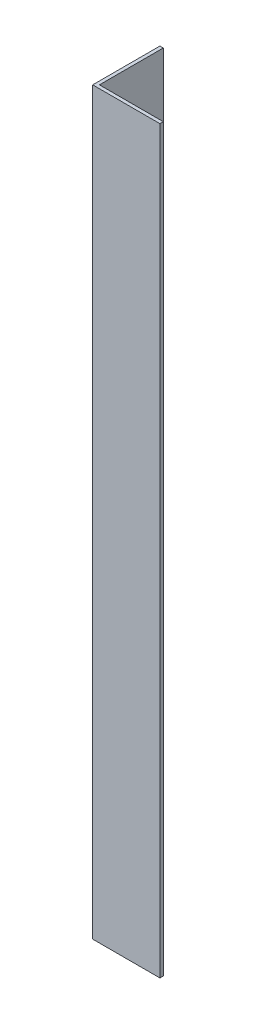
from build123d import *

# Parameters (mm, degrees)
EXTRUDE_1_DEPTH     = 220
SKETCH_2_R          = 4.25
CUT_EXTRUDE_1_DEPTH = 2


with BuildPart() as part:
    # Эскиз1 → Бобышка-Вытянуть1 (new body)
    with BuildSketch(Plane(origin=(0, 0, 0), x_dir=(1, 0, 0), z_dir=(0, 1, 0))):
        Polygon((0, 0), (0, 20), (1, 20), (1, 1), (20, 1), (20, 0), align=None)
    extrude(amount=EXTRUDE_1_DEPTH)

    # Эскиз2 → Вырез-Вытянуть1 (cut, through all)
    with BuildSketch(Plane(origin=(1, 0, 0), x_dir=(0, 0, -1), z_dir=(1, 0, 0))):
        with Locations((10.5, 180)):
            Circle(SKETCH_2_R)
        with Locations((10.5, 110)):
            Circle(SKETCH_2_R)
        with Locations((10.5, 40)):
            Circle(SKETCH_2_R)
    extrude(amount=-CUT_EXTRUDE_1_DEPTH, mode=Mode.SUBTRACT)


solid = part.part
